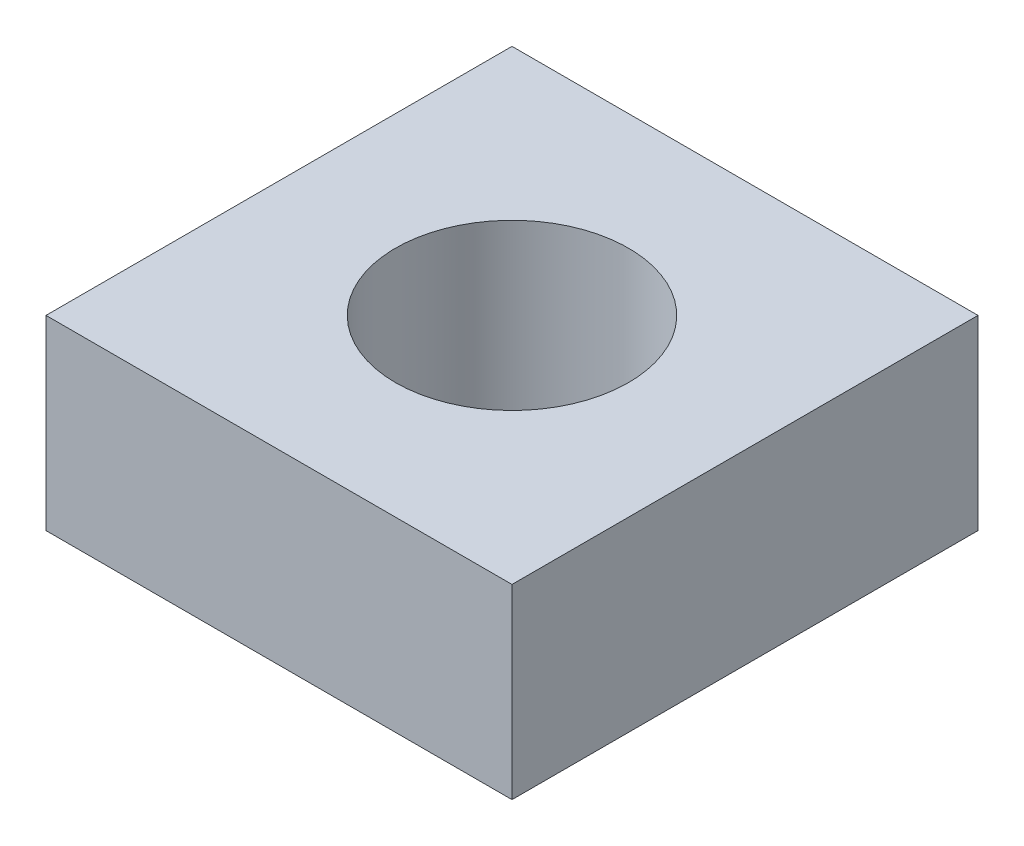
from build123d import *

# Parameters (mm, degrees)
SKETCH1_W           = 50
SKETCH1_H           = 50
SKETCH1_R           = 12.5
BOSS_EXTRUDE1_DEPTH = 20


with BuildPart() as part:
    # Sketch1 → Boss-Extrude1 (new body)
    with BuildSketch(Plane(origin=(0, 0, 0), x_dir=(1, 0, 0), z_dir=(0, 1, 0))):
        Rectangle(SKETCH1_W, SKETCH1_H)
        Circle(SKETCH1_R, mode=Mode.SUBTRACT)
    extrude(amount=BOSS_EXTRUDE1_DEPTH)


solid = part.part
